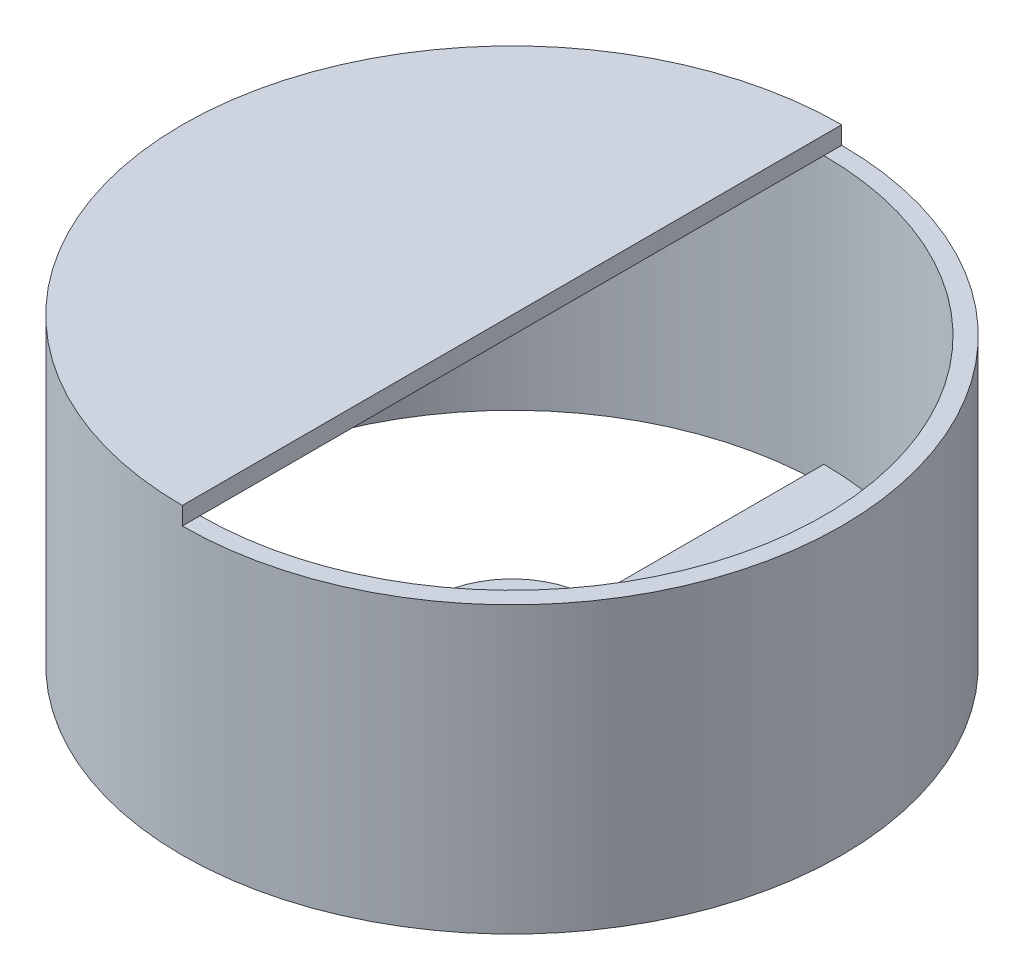
from build123d import *

# Parameters (mm, degrees)
SKETCH1_R           = 18.5
SKETCH1_R_2         = 17.5
SKETCH1_R_3         = 4.5
SKETCH1_R_4         = 3.5
BOSS_EXTRUDE1_DEPTH = 1
SKETCH2_R           = 18.5
SKETCH2_R_2         = 17.5
BOSS_EXTRUDE2_DEPTH = 15
BOSS_EXTRUDE3_DEPTH = 1


with BuildPart() as part:
    # Sketch1 → Boss-Extrude1 (new body)
    with BuildSketch(Plane(origin=(0, 0, 0), x_dir=(1, 0, 0), z_dir=(0, 1, 0))):
        with Locations(Location((0, 0, 0), (0, 0, 270))):
            Circle(SKETCH1_R)
        Circle(SKETCH1_R_2, mode=Mode.SUBTRACT)
        Circle(SKETCH1_R_3)
        with Locations(Location((0, 0, 0), (0, 0, 270))):
            Circle(SKETCH1_R_4, mode=Mode.SUBTRACT)
        with BuildLine():
            Line((0, 17.5), (0, 4.5))
            ThreePointArc((0, 4.5), (3.181980515, 3.181980515), (4.5, 0))
            ThreePointArc((4.5, 0), (3.181980515, -3.181980515), (0, -4.5))
            Line((0, -4.5), (0, -17.5))
            ThreePointArc((0, -17.5), (12.374368671, -12.374368671), (17.5, 0))
            ThreePointArc((17.5, 0), (12.374368671, 12.374368671), (0, 17.5))
        make_face()
    extrude(amount=BOSS_EXTRUDE1_DEPTH)

    # Sketch2 → Boss-Extrude2 (add)
    with BuildSketch(Plane(origin=(0, 1, 0), x_dir=(1, 0, 0), z_dir=(0, 1, 0))):
        with Locations(Location((0, 0, 0), (0, 0, 270))):
            Circle(SKETCH2_R)
        with Locations(Location((0, 0, 0), (0, 0, 270))):
            Circle(SKETCH2_R_2, mode=Mode.SUBTRACT)
    extrude(amount=BOSS_EXTRUDE2_DEPTH)

    # Sketch3 → Boss-Extrude3 (add)
    with BuildSketch(Plane(origin=(0, 16, 0), x_dir=(1, 0, 0), z_dir=(0, 1, 0))):
        with BuildLine():
            Line((0, 18.5), (0, -18.5))
            ThreePointArc((0, -18.5), (-18.5, 0), (0, 18.5))
        make_face()
    extrude(amount=BOSS_EXTRUDE3_DEPTH)


solid = part.part
